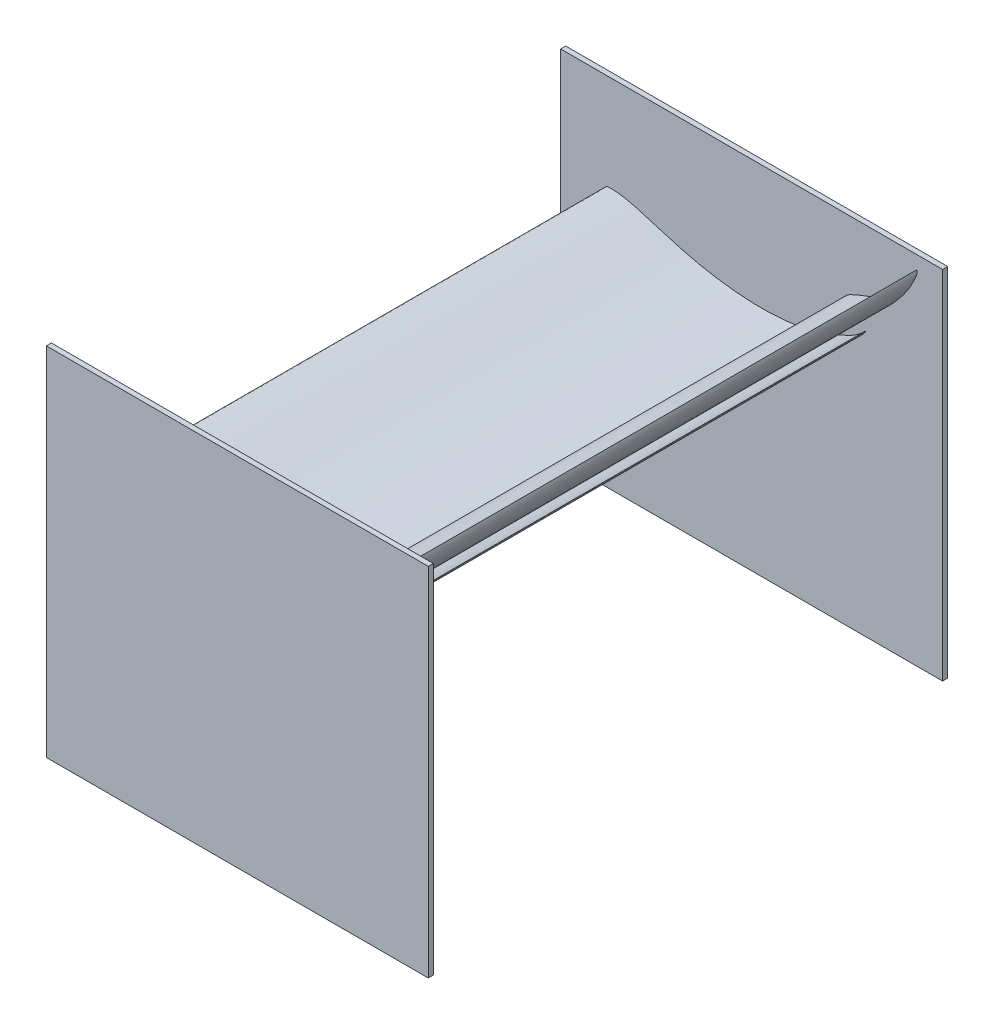
from build123d import *

# Parameters (mm, degrees)
BOSS_EXTRUDE4_DEPTH   = 1000
BOSS_EXTRUDE4_2_DEPTH = 1000
SKETCH8_4_W           = 750
SKETCH8_4_H           = 700
BOSS_EXTRUDE6_DEPTH   = 10


with BuildPart() as part:
    # Sketch8 → Boss-Extrude4 (new body)
    with BuildSketch(Plane.XY):
        with BuildLine():
            add(Edge.make_bspline(
                [(735.098118119, 1062.259241818), (734.601409278, 1061.857352571), (733.913894671, 1061.258779434), (733.159708622, 1060.5025364), (732.820827239, 1060.146869878), (732.655570392, 1059.929168645), (732.573068322, 1059.792866332), (732.51546198, 1059.664130084), (732.478217652, 1059.539063198), (732.457280183, 1059.398554207), (732.455019211, 1059.218374618), (732.487388993, 1058.947328848), (732.555192641, 1058.677214817), (732.671564082, 1058.306120005), (732.840580219, 1057.896064811), (733.130564106, 1057.391023864), (733.450516164, 1056.964543005), (733.92015365, 1056.444226915), (734.693470711, 1055.753656785), (735.764754895, 1055.018574476), (737.078145767, 1054.203507323), (738.504955291, 1053.434459791), (740.228993812, 1052.73578844), (742.096436271, 1052.161812681), (744.171746462, 1051.698844663), (746.457605026, 1051.361571167), (748.940870175, 1051.177117957), (751.593659792, 1051.158399578), (754.424208971, 1051.31364925), (757.458013407, 1051.649803777), (760.17786487, 1052.095508262), (763.046698103, 1052.688946304), (766.005873398, 1053.431395181), (769.513468846, 1054.504269348), (773.072597893, 1055.7886681), (776.681340719, 1057.289681392), (780.329006893, 1059.009670046), (782.926041541, 1060.377638339), (785.696888614, 1061.913077581), (788.667003133, 1063.650963755), (793.033896011, 1066.395954055), (797.69686594, 1069.502549142), (802.485976439, 1072.926218586), (807.111077859, 1076.487798442), (811.491695414, 1080.124490735), (815.743007195, 1083.903149636), (820.012768163, 1087.95181423), (824.293833285, 1092.275620465), (828.597562446, 1096.892248082), (832.895111152, 1101.772323208), (837.247326341, 1106.990161336), (841.673400242, 1112.580147544), (845.963267492, 1118.262919017), (849.968867594, 1123.852668386), (853.688158888, 1129.344361564), (857.189200541, 1134.858020569), (860.503246924, 1140.470441622), (863.557661854, 1146.037150497), (866.241428188, 1151.329782553), (868.489711235, 1156.094644766), (870.144915492, 1159.938008884), (871.314586064, 1162.921181838), (872.100910965, 1165.207905314), (872.621464287, 1167.168377237), (872.947759511, 1169.031611186), (873.069342295, 1171.002533427), (873.027898115, 1172.534986125), (872.737757495, 1175.698504336), (872.56963235, 1171.365903117), (872.070813006, 1169.395329562), (871.409997142, 1166.623070983), (870.54052868, 1164.076504516), (869.463228002, 1161.41197751), (868.037840836, 1158.378010011), (865.822659935, 1154.203002295), (863.20638468, 1149.570582534), (860.449724759, 1144.861590264), (857.954159387, 1140.965023681), (855.349867209, 1137.216196327), (852.597562342, 1133.597445581), (849.657125195, 1130.064916079), (846.589134724, 1126.691224611), (843.315075993, 1123.381253499), (839.706713798, 1119.971912039), (835.641082992, 1116.337070731), (831.186557971, 1112.602057559), (826.519959747, 1108.95262959), (821.607637666, 1105.381266916), (816.452121825, 1101.892481871), (810.984864405, 1098.435926476), (805.275264371, 1095.03588268), (799.365591639, 1091.729205792), (793.383037543, 1088.620884002), (787.449932647, 1085.77756089), (781.34503369, 1083.054371724), (774.758048101, 1080.300324379), (767.484126813, 1077.437376941), (760.262402442, 1074.700461462), (753.89146132, 1072.183031963), (748.941913043, 1070.076741063), (745.044557852, 1068.282985183), (741.864742844, 1066.66151286), (739.188456537, 1065.130575403), (736.974590728, 1063.690754872), (735.668112419, 1062.720426643), (735.098118119, 1062.259241818)],
                knots=[0, 0, 0, 0, 0.004864987, 0.006932545, 0.008137884, 0.008601497, 0.009011818, 0.009348653, 0.009673164, 0.01000266, 0.010427575, 0.011041817, 0.012076633, 0.012543472, 0.014004596, 0.015443582, 0.016968766, 0.018056068, 0.020779525, 0.024840634, 0.027935886, 0.032555454, 0.037166363, 0.042082108, 0.047421878, 0.05334819, 0.059667447, 0.066374566, 0.073542337, 0.08124902, 0.089615403, 0.094526367, 0.103562345, 0.112843808, 0.122455999, 0.132373756, 0.142605348, 0.153165588, 0.154726061, 0.166736317, 0.179371763, 0.194012659, 0.209411027, 0.224206692, 0.238469752, 0.252771691, 0.267526239, 0.283284172, 0.299113579, 0.315597401, 0.332811403, 0.350865811, 0.369905471, 0.387043716, 0.403243825, 0.420423249, 0.436786871, 0.45288503, 0.468782716, 0.481983436, 0.493011687, 0.500654809, 0.506381799, 0.511437541, 0.516043967, 0.520925914, 0.525830531, 0.529953559, 0.536609682, 0.543291188, 0.550106034, 0.557026955, 0.564113346, 0.571894396, 0.582580083, 0.60009418, 0.612424841, 0.624138462, 0.63533215, 0.647187483, 0.658759225, 0.670332543, 0.681912601, 0.694215176, 0.708142393, 0.723449252, 0.738488352, 0.753260173, 0.769704083, 0.785898216, 0.802525573, 0.820318822, 0.837475337, 0.85387235, 0.870428329, 0.888390886, 0.908253005, 0.929971274, 0.947220557, 0.960430628, 0.970941392, 0.97989584, 0.987611289, 0.994417222, 1, 1, 1, 1], degree=3))
        make_face()
    extrude(amount=BOSS_EXTRUDE4_DEPTH)



with BuildPart() as body_2:
    # Sketch8 → Boss-Extrude4 2 (new body)
    with BuildSketch(Plane.XY):
        with BuildLine():
            add(Edge.make_bspline(
                [(273, 1012.259241818), (271.201415149, 1012.234358284), (268.638301196, 1012.10630654), (265.653250332, 1011.745382351), (264.284362196, 1011.548108706), (263.539792154, 1011.353967566), (263.120011119, 1011.195929843), (262.768488909, 1011.011307562), (262.46841133, 1010.799368061), (262.177544142, 1010.524877385), (261.858964948, 1010.130096837), (261.458880229, 1009.473970816), (261.138827884, 1008.758239213), (260.750508018, 1007.734524406), (260.410879649, 1006.532974719), (260.173629484, 1004.91070667), (260.139417442, 1003.410127333), (260.27313463, 1001.441396727), (260.78255566, 998.567405306), (261.873874691, 995.076346138), (263.361744472, 990.986939376), (265.180686227, 986.80198002), (267.779838812, 982.255471431), (270.913341047, 977.73532561), (274.700021761, 973.099063311), (279.171373055, 968.374519326), (284.345522139, 963.644591001), (290.183245149, 958.98638135), (296.717094047, 954.403777518), (304.01556017, 949.867758319), (310.809942199, 946.120548541), (318.191111112, 942.440974345), (326.031527311, 938.933915931), (335.66058673, 935.203604147), (345.771810983, 931.851683832), (356.369810057, 928.892759608), (367.435035994, 926.350660791), (375.56270322, 924.858052745), (384.366454556, 923.433542635), (393.963489381, 922.110227338), (408.404140054, 920.584624285), (424.129292769, 919.343930143), (440.685400214, 918.58535383), (457.118588273, 918.417389982), (473.141485477, 918.841128813), (489.125316682, 919.804059999), (505.619878679, 921.332372741), (522.618298741, 923.449867137), (540.176483884, 926.175896096), (558.179483876, 929.4956584), (576.891280693, 933.467710063), (596.414186543, 938.134739827), (615.79716274, 943.244139596), (634.38919922, 948.642417751), (652.177016954, 954.321987683), (669.520103149, 960.429996543), (686.621272384, 967.081991385), (703.068353621, 974.084680917), (718.218244575, 981.125930994), (731.485958784, 987.757185122), (741.837530826, 993.381442418), (749.617640535, 997.947201275), (755.33738571, 1001.638958927), (759.901218231, 1005.071297864), (763.865952974, 1008.626538537), (767.56509963, 1012.776351993), (770.140396094, 1016.239610207), (775.003986102, 1023.745036678), (767.091693749, 1014.450116045), (762.558375476, 1010.957598654), (756.271364407, 1005.972981165), (749.915414367, 1001.850921772), (742.894264123, 997.829531351), (734.45988441, 993.596407296), (722.291975763, 988.212819774), (708.440436227, 982.515080662), (694.144979431, 976.892214694), (681.841199806, 972.612751127), (669.553939318, 968.849439376), (657.165523926, 965.631565479), (644.510850096, 962.931905094), (631.850350445, 960.805721591), (618.84474275, 959.1791748), (604.926422901, 957.914539319), (589.603774286, 956.946708621), (573.246215926, 956.434022709), (556.568313851, 956.47980846), (539.482515985, 957.125989228), (522.00227417, 958.378146995), (503.888277237, 960.244165176), (485.336355769, 962.656998122), (466.504189143, 965.624637589), (447.855952684, 969.158051916), (429.77833229, 973.191816944), (411.529627983, 977.790405896), (392.160420714, 983.159709982), (371.081584088, 989.483541487), (350.33759286, 995.995425316), (331.858264003, 1001.512342352), (317.239829948, 1005.465334797), (305.493691746, 1008.278742569), (295.635216434, 1010.224620207), (287.048551222, 1011.494523185), (279.643741662, 1012.161282277), (275.063951815, 1012.287796721), (273, 1012.259241818)],
                knots=[0, 0, 0, 0, 0.004864987, 0.006932545, 0.008137884, 0.008601497, 0.009011818, 0.009348653, 0.009673164, 0.01000266, 0.010427575, 0.011041817, 0.012076633, 0.012543472, 0.014004596, 0.015443582, 0.016968766, 0.018056068, 0.020779525, 0.024840634, 0.027935886, 0.032555454, 0.037166363, 0.042082108, 0.047421878, 0.05334819, 0.059667447, 0.066374566, 0.073542337, 0.08124902, 0.089615403, 0.094526367, 0.103562345, 0.112843808, 0.122455999, 0.132373756, 0.142605348, 0.153165588, 0.154726061, 0.166736317, 0.179371763, 0.194012659, 0.209411027, 0.224206692, 0.238469752, 0.252771691, 0.267526239, 0.283284172, 0.299113579, 0.315597401, 0.332811403, 0.350865811, 0.369905471, 0.387043716, 0.403243825, 0.420423249, 0.436786871, 0.45288503, 0.468782716, 0.481983436, 0.493011687, 0.500654809, 0.506381799, 0.511437541, 0.516043967, 0.520925914, 0.525830531, 0.529953559, 0.536609682, 0.543291188, 0.550106034, 0.557026955, 0.564113346, 0.571894396, 0.582580083, 0.60009418, 0.612424841, 0.624138462, 0.63533215, 0.647187483, 0.658759225, 0.670332543, 0.681912601, 0.694215176, 0.708142393, 0.723449252, 0.738488352, 0.753260173, 0.769704083, 0.785898216, 0.802525573, 0.820318822, 0.837475337, 0.85387235, 0.870428329, 0.888390886, 0.908253005, 0.929971274, 0.947220557, 0.960430628, 0.970941392, 0.97989584, 0.987611289, 0.994417222, 1, 1, 1, 1], degree=3))
        make_face()
    extrude(amount=BOSS_EXTRUDE4_2_DEPTH)


with BuildPart() as part_1:
    add(part.part)

    add(body_2.part)  # Boss-Extrude6 merges body 2
    # Sketch8_4 → Boss-Extrude6 (add)
    with BuildSketch(Plane.XY):
        with Locations((548, 850)):
            Rectangle(SKETCH8_4_W, SKETCH8_4_H)
    boss_extrude6 = extrude(amount=-BOSS_EXTRUDE6_DEPTH)

    # Mirror1: Boss-Extrude6 across plane
    add(boss_extrude6.mirror(Plane.XY.offset(500)))


solid = part_1.part
